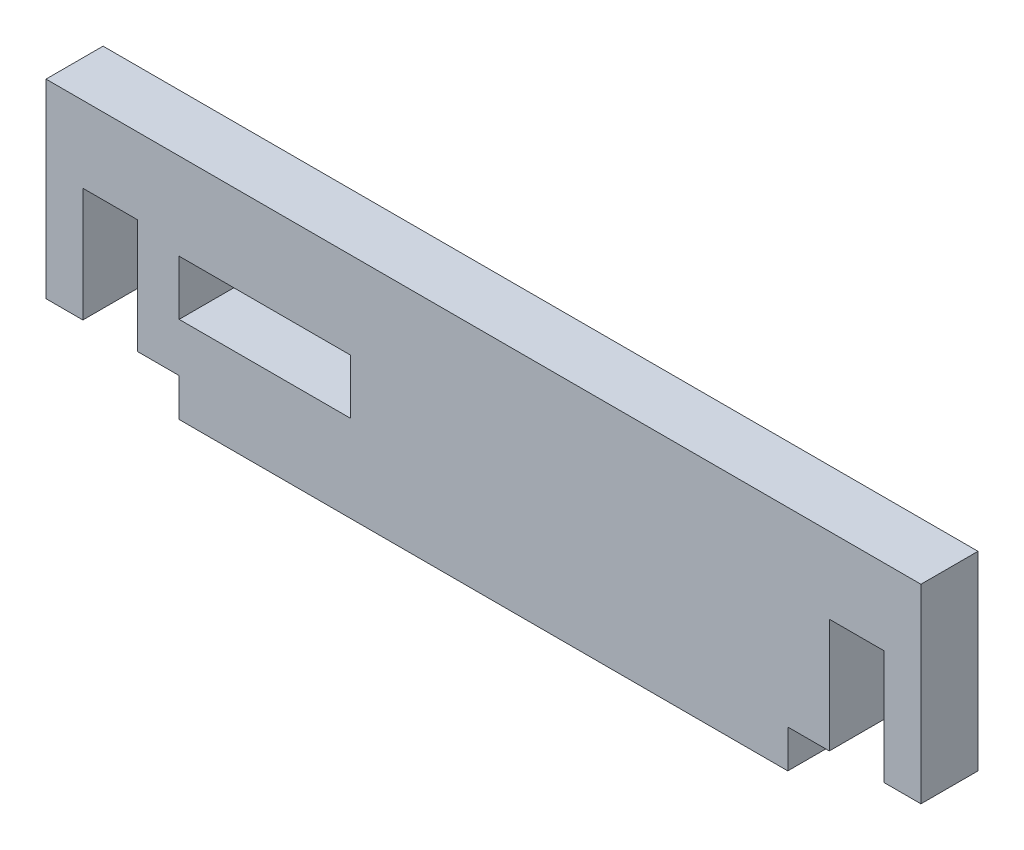
from build123d import *

# Parameters (mm, degrees)
CROQUIS1_W              = 9
CROQUIS1_H              = 2.877
SALIENTE_EXTRUIR1_DEPTH = 3


with BuildPart() as part:
    # Croquis1 → Saliente-Extruir1 (new body)
    with BuildSketch(Plane.XY):
        Polygon((0, 2), (0, 0), (32, 0), (32, 2), (34.1845, 2), (34.1845, 8), (37.0615, 8), (37.0615, 2), (39, 2), (39, 12), (-7, 12), (-7, 2), (-5.0615, 2), (-5.0615, 8), (-2.1845, 8), (-2.1845, 2), align=None)
        with Locations((4.5, 5.9985)):
            Rectangle(CROQUIS1_W, CROQUIS1_H, mode=Mode.SUBTRACT)
    extrude(amount=SALIENTE_EXTRUIR1_DEPTH)


solid = part.part
